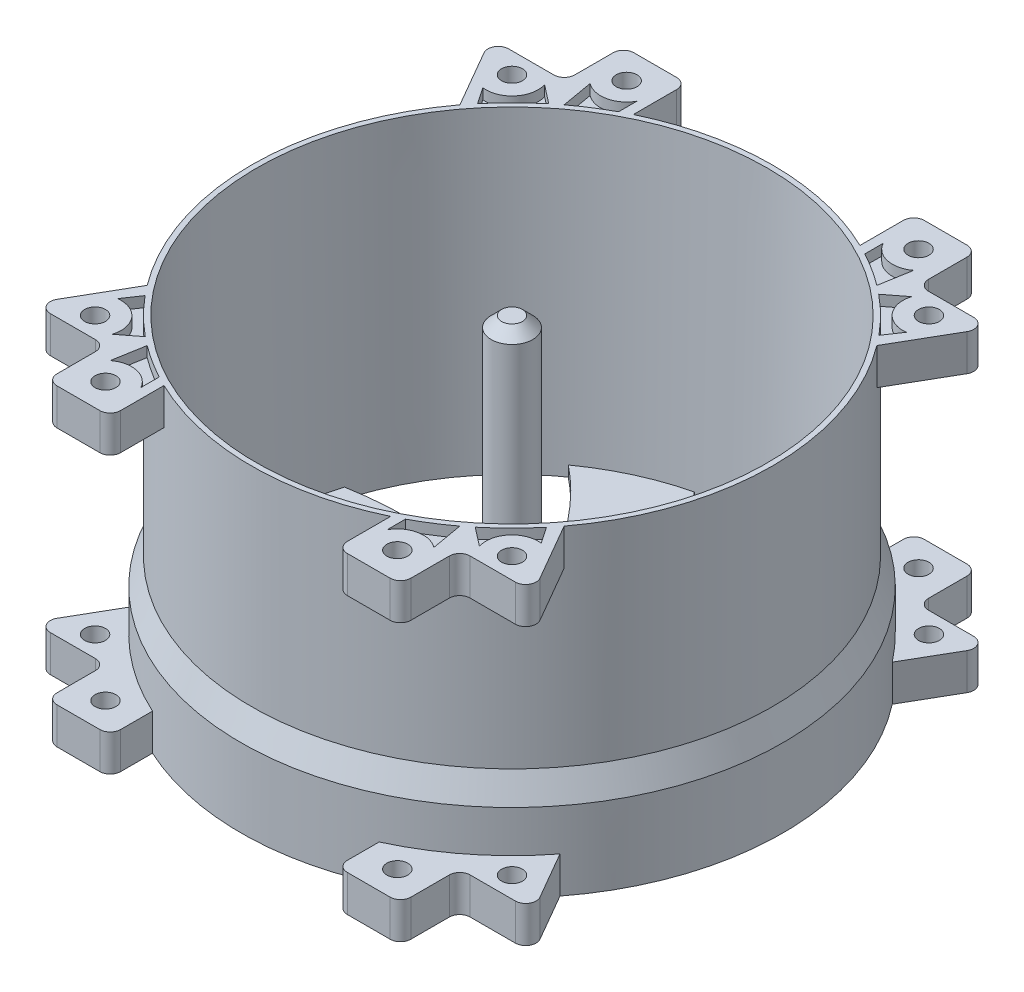
from build123d import *

# Parameters (mm, degrees)
SKETCH3_R               = 1
BOSS_EXTRUDE2_DEPTH     = 3.5
MIRROR2_COPY_1_SKETCH_R = 1
MIRROR2_COPY_1_DEPTH    = 3.5
MIRROR3_COPY_1_SKETCH_R = 1
MIRROR3_COPY_1_DEPTH    = 3.5
MIRROR3_COPY_2_SKETCH_R = 1
MIRROR3_COPY_2_DEPTH    = 3.5
MIRROR3_COPY_3_SKETCH_R = 1
MIRROR3_COPY_3_DEPTH    = 3.5
CUT_EXTRUDE1_DEPTH      = 1
MIRROR5_COPY_1_DEPTH    = 1
MIRROR7_COPY_1_DEPTH    = 1
MIRROR7_COPY_2_DEPTH    = 1
MIRROR7_COPY_3_DEPTH    = 1
BOSS_EXTRUDE3_DEPTH     = 1
SKETCH7_R               = 2.5
BOSS_EXTRUDE4_DEPTH     = 10
SKETCH8_R               = 2
BOSS_EXTRUDE5_DEPTH     = 19
CHAMFER1_SIZE           = 1


with BuildPart() as part:
    # Sketch1 → Revolve1 (revolve)
    with BuildSketch(Plane.XY):
        Polygon((-24.5, 30), (-25, 30), (-25, 10), (-26, 7.5), (-26, 0), (-23.75, 0), (-24, 10), align=None)
    revolve(axis=Axis((0, 0, 0), (0, 1, 0)))

    # Sketch3 → Boss-Extrude2 (add)
    with BuildSketch(Plane(origin=(0, 0, 0), x_dir=(1, 0, 0), z_dir=(0, 1, 0))):
        with BuildLine():
            Line((-10.872673426, 22.511885141), (-10.872673426, 26.672563638))
            ThreePointArc((-10.872673426, 26.672563638), (-11.165566644, 27.379670419), (-11.872673426, 27.672563638))
            Line((-11.872673426, 27.672563638), (-15.975816202, 27.672563638))
            ThreePointArc((-15.975816202, 27.672563638), (-16.682922984, 27.379670419), (-16.975816202, 26.672563638))
            Line((-16.975816202, 26.672563638), (-16.975816202, 22.989545507))
            ThreePointArc((-16.975816202, 22.989545507), (-17.268709421, 22.282438726), (-17.975816202, 21.989545507))
            Line((-17.975816202, 21.989545507), (-22.303365172, 21.989545507))
            ThreePointArc((-22.303365172, 21.989545507), (-23.169390576, 21.489545507), (-23.169390576, 20.489545507))
            Line((-23.169390576, 20.489545507), (-20, 15))
            ThreePointArc((-20, 15), (-15.886711293, 19.303170835), (-10.872673426, 22.511885141))
        make_face()
        with Locations((-14, 25)):
            Circle(SKETCH3_R, mode=Mode.SUBTRACT)
        with Locations((-20, 20)):
            Circle(SKETCH3_R, mode=Mode.SUBTRACT)
    boss_extrude2 = extrude(amount=BOSS_EXTRUDE2_DEPTH)

    # Mirror1: Boss-Extrude2 across plane
    add(boss_extrude2.mirror(Plane(origin=(0, 0, 0), x_dir=(0, 0, 1), z_dir=(1, 0, 0))))

    # Mirror2: Boss-Extrude2 across plane
    add(boss_extrude2.mirror(Plane.XY))

    # Mirror2 copy 1 sketch → Mirror2 copy 1 (add)
    with BuildSketch(Plane(origin=(0, 0, 0), x_dir=(-1, 0, 0), z_dir=(0, 1, 0))):
        with BuildLine():
            Line((-10.872673426, 22.511885141), (-10.872673426, 26.672563638))
            ThreePointArc((-10.872673426, 26.672563638), (-11.165566644, 27.379670419), (-11.872673426, 27.672563638))
            Line((-11.872673426, 27.672563638), (-15.975816202, 27.672563638))
            ThreePointArc((-15.975816202, 27.672563638), (-16.682922984, 27.379670419), (-16.975816202, 26.672563638))
            Line((-16.975816202, 26.672563638), (-16.975816202, 22.989545507))
            ThreePointArc((-16.975816202, 22.989545507), (-17.268709421, 22.282438726), (-17.975816202, 21.989545507))
            Line((-17.975816202, 21.989545507), (-22.303365172, 21.989545507))
            ThreePointArc((-22.303365172, 21.989545507), (-23.169390576, 21.489545507), (-23.169390576, 20.489545507))
            Line((-23.169390576, 20.489545507), (-20, 15))
            ThreePointArc((-20, 15), (-15.886711293, 19.303170835), (-10.872673426, 22.511885141))
        make_face()
        with Locations((-14, 25)):
            Circle(MIRROR2_COPY_1_SKETCH_R, mode=Mode.SUBTRACT)
        with Locations((-20, 20)):
            Circle(MIRROR2_COPY_1_SKETCH_R, mode=Mode.SUBTRACT)
    extrude(amount=MIRROR2_COPY_1_DEPTH)

    # Mirror3: Boss-Extrude2 across plane
    add(boss_extrude2.mirror(Plane(origin=(0, 15, 0), x_dir=(0, 0, 1), z_dir=(0, -1, 0))))

    # Mirror3 copy 1 sketch → Mirror3 copy 1 (add)
    with BuildSketch(Plane.XZ.offset(-30)):
        with BuildLine():
            Line((-10.872673426, 22.511885141), (-10.872673426, 26.672563638))
            ThreePointArc((-10.872673426, 26.672563638), (-11.165566644, 27.379670419), (-11.872673426, 27.672563638))
            Line((-11.872673426, 27.672563638), (-15.975816202, 27.672563638))
            ThreePointArc((-15.975816202, 27.672563638), (-16.682922984, 27.379670419), (-16.975816202, 26.672563638))
            Line((-16.975816202, 26.672563638), (-16.975816202, 22.989545507))
            ThreePointArc((-16.975816202, 22.989545507), (-17.268709421, 22.282438726), (-17.975816202, 21.989545507))
            Line((-17.975816202, 21.989545507), (-22.303365172, 21.989545507))
            ThreePointArc((-22.303365172, 21.989545507), (-23.169390576, 21.489545507), (-23.169390576, 20.489545507))
            Line((-23.169390576, 20.489545507), (-20, 15))
            ThreePointArc((-20, 15), (-15.886711293, 19.303170835), (-10.872673426, 22.511885141))
        make_face()
        with Locations((-14, 25)):
            Circle(MIRROR3_COPY_1_SKETCH_R, mode=Mode.SUBTRACT)
        with Locations((-20, 20)):
            Circle(MIRROR3_COPY_1_SKETCH_R, mode=Mode.SUBTRACT)
    extrude(amount=MIRROR3_COPY_1_DEPTH)

    # Mirror3 copy 2 sketch → Mirror3 copy 2 (add)
    with BuildSketch(Plane(origin=(0, 30, 0), x_dir=(-1, 0, 0), z_dir=(0, -1, 0))):
        with BuildLine():
            Line((-10.872673426, -22.511885141), (-10.872673426, -26.672563638))
            ThreePointArc((-10.872673426, -26.672563638), (-11.165566644, -27.379670419), (-11.872673426, -27.672563638))
            Line((-11.872673426, -27.672563638), (-15.975816202, -27.672563638))
            ThreePointArc((-15.975816202, -27.672563638), (-16.682922984, -27.379670419), (-16.975816202, -26.672563638))
            Line((-16.975816202, -26.672563638), (-16.975816202, -22.989545507))
            ThreePointArc((-16.975816202, -22.989545507), (-17.268709421, -22.282438726), (-17.975816202, -21.989545507))
            Line((-17.975816202, -21.989545507), (-22.303365172, -21.989545507))
            ThreePointArc((-22.303365172, -21.989545507), (-23.169390576, -21.489545507), (-23.169390576, -20.489545507))
            Line((-23.169390576, -20.489545507), (-20, -15))
            ThreePointArc((-20, -15), (-15.886711293, -19.303170835), (-10.872673426, -22.511885141))
        make_face()
        with Locations((-14, -25)):
            Circle(MIRROR3_COPY_2_SKETCH_R, mode=Mode.SUBTRACT)
        with Locations((-20, -20)):
            Circle(MIRROR3_COPY_2_SKETCH_R, mode=Mode.SUBTRACT)
    extrude(amount=MIRROR3_COPY_2_DEPTH)

    # Mirror3 copy 3 sketch → Mirror3 copy 3 (add)
    with BuildSketch(Plane(origin=(0, 30, 0), x_dir=(-1, 0, 0), z_dir=(0, -1, 0))):
        with BuildLine():
            Line((-10.872673426, 22.511885141), (-10.872673426, 26.672563638))
            ThreePointArc((-10.872673426, 26.672563638), (-11.165566644, 27.379670419), (-11.872673426, 27.672563638))
            Line((-11.872673426, 27.672563638), (-15.975816202, 27.672563638))
            ThreePointArc((-15.975816202, 27.672563638), (-16.682922984, 27.379670419), (-16.975816202, 26.672563638))
            Line((-16.975816202, 26.672563638), (-16.975816202, 22.989545507))
            ThreePointArc((-16.975816202, 22.989545507), (-17.268709421, 22.282438726), (-17.975816202, 21.989545507))
            Line((-17.975816202, 21.989545507), (-22.303365172, 21.989545507))
            ThreePointArc((-22.303365172, 21.989545507), (-23.169390576, 21.489545507), (-23.169390576, 20.489545507))
            Line((-23.169390576, 20.489545507), (-20, 15))
            ThreePointArc((-20, 15), (-15.886711293, 19.303170835), (-10.872673426, 22.511885141))
        make_face()
        with Locations((-14, 25)):
            Circle(MIRROR3_COPY_3_SKETCH_R, mode=Mode.SUBTRACT)
        with Locations((-20, 20)):
            Circle(MIRROR3_COPY_3_SKETCH_R, mode=Mode.SUBTRACT)
    extrude(amount=MIRROR3_COPY_3_DEPTH)

    # Sketch4 → Cut-Extrude1 (cut)
    with BuildSketch(Plane(origin=(0, 30, 0), x_dir=(1, 0, 0), z_dir=(0, 1, 0))):
        with BuildLine():
            Line((-19.251721054, 15.949019922), (-20.314309044, 17.519836734))
            ThreePointArc((-20.314309044, 17.519836734), (-18.085884655, 18.391845018), (-17.611180005, 20.737250996))
            Line((-17.611180005, 20.737250996), (-15.826569138, 19.352511706))
            ThreePointArc((-15.826569138, 19.352511706), (-17.621508158, 17.733653042), (-19.251721054, 15.949019922))
        make_face()
        with BuildLine():
            Line((-11.811012201, 22.034064328), (-11.811012201, 23.792385651))
            ThreePointArc((-11.811012201, 23.792385651), (-13.488202854, 22.552947961), (-15.521536705, 23.016335195))
            Line((-15.521536705, 23.016335195), (-15, 20))
            ThreePointArc((-15, 20), (-13.444030208, 21.077429914), (-11.811012201, 22.034064328))
        make_face()
    cut_extrude1 = extrude(amount=-CUT_EXTRUDE1_DEPTH, mode=Mode.SUBTRACT)

    # Mirror4: Cut-Extrude1 across plane
    add(cut_extrude1.mirror(Plane.XY), mode=Mode.SUBTRACT)

    # Mirror5: Cut-Extrude1 across plane
    add(cut_extrude1.mirror(Plane(origin=(0, 0, 0), x_dir=(0, 0, 1), z_dir=(1, 0, 0))), mode=Mode.SUBTRACT)

    # Mirror5 copy 1 sketch → Mirror5 copy 1 (cut)
    with BuildSketch(Plane(origin=(0, 30, 0), x_dir=(-1, 0, 0), z_dir=(0, 1, 0))):
        with BuildLine():
            Line((-19.251721054, 15.949019922), (-20.314309044, 17.519836734))
            ThreePointArc((-20.314309044, 17.519836734), (-18.085884655, 18.391845018), (-17.611180005, 20.737250996))
            Line((-17.611180005, 20.737250996), (-15.826569138, 19.352511706))
            ThreePointArc((-15.826569138, 19.352511706), (-17.621508158, 17.733653042), (-19.251721054, 15.949019922))
        make_face()
        with BuildLine():
            Line((-11.811012201, 22.034064328), (-11.811012201, 23.792385651))
            ThreePointArc((-11.811012201, 23.792385651), (-13.488202854, 22.552947961), (-15.521536705, 23.016335195))
            Line((-15.521536705, 23.016335195), (-15, 20))
            ThreePointArc((-15, 20), (-13.444030208, 21.077429914), (-11.811012201, 22.034064328))
        make_face()
    extrude(amount=-MIRROR5_COPY_1_DEPTH, mode=Mode.SUBTRACT)

    # Mirror7: Cut-Extrude1 across plane
    add(cut_extrude1.mirror(Plane(origin=(0, 15, 0), x_dir=(0, 0, 1), z_dir=(0, -1, 0))), mode=Mode.SUBTRACT)

    # Mirror7 copy 1 sketch → Mirror7 copy 1 (cut)
    with BuildSketch(Plane(origin=(0, 0, 0), x_dir=(-1, 0, 0), z_dir=(0, -1, 0))):
        with BuildLine():
            Line((-19.251721054, 15.949019922), (-20.314309044, 17.519836734))
            ThreePointArc((-20.314309044, 17.519836734), (-18.085884655, 18.391845018), (-17.611180005, 20.737250996))
            Line((-17.611180005, 20.737250996), (-15.826569138, 19.352511706))
            ThreePointArc((-15.826569138, 19.352511706), (-17.621508158, 17.733653042), (-19.251721054, 15.949019922))
        make_face()
        with BuildLine():
            Line((-11.811012201, 22.034064328), (-11.811012201, 23.792385651))
            ThreePointArc((-11.811012201, 23.792385651), (-13.488202854, 22.552947961), (-15.521536705, 23.016335195))
            Line((-15.521536705, 23.016335195), (-15, 20))
            ThreePointArc((-15, 20), (-13.444030208, 21.077429914), (-11.811012201, 22.034064328))
        make_face()
    extrude(amount=-MIRROR7_COPY_1_DEPTH, mode=Mode.SUBTRACT)

    # Mirror7 copy 2 sketch → Mirror7 copy 2 (cut)
    with BuildSketch(Plane(origin=(0, 0, 0), x_dir=(-1, 0, 0), z_dir=(0, -1, 0))):
        with BuildLine():
            Line((-19.251721054, -15.949019922), (-20.314309044, -17.519836734))
            ThreePointArc((-20.314309044, -17.519836734), (-18.085884655, -18.391845018), (-17.611180005, -20.737250996))
            Line((-17.611180005, -20.737250996), (-15.826569138, -19.352511706))
            ThreePointArc((-15.826569138, -19.352511706), (-17.621508158, -17.733653042), (-19.251721054, -15.949019922))
        make_face()
        with BuildLine():
            Line((-11.811012201, -22.034064328), (-11.811012201, -23.792385651))
            ThreePointArc((-11.811012201, -23.792385651), (-13.488202854, -22.552947961), (-15.521536705, -23.016335195))
            Line((-15.521536705, -23.016335195), (-15, -20))
            ThreePointArc((-15, -20), (-13.444030208, -21.077429914), (-11.811012201, -22.034064328))
        make_face()
    extrude(amount=-MIRROR7_COPY_2_DEPTH, mode=Mode.SUBTRACT)

    # Mirror7 copy 3 sketch → Mirror7 copy 3 (cut)
    with BuildSketch(Plane.XZ):
        with BuildLine():
            Line((-19.251721054, 15.949019922), (-20.314309044, 17.519836734))
            ThreePointArc((-20.314309044, 17.519836734), (-18.085884655, 18.391845018), (-17.611180005, 20.737250996))
            Line((-17.611180005, 20.737250996), (-15.826569138, 19.352511706))
            ThreePointArc((-15.826569138, 19.352511706), (-17.621508158, 17.733653042), (-19.251721054, 15.949019922))
        make_face()
        with BuildLine():
            Line((-11.811012201, 22.034064328), (-11.811012201, 23.792385651))
            ThreePointArc((-11.811012201, 23.792385651), (-13.488202854, 22.552947961), (-15.521536705, 23.016335195))
            Line((-15.521536705, 23.016335195), (-15, 20))
            ThreePointArc((-15, 20), (-13.444030208, 21.077429914), (-11.811012201, 22.034064328))
        make_face()
    extrude(amount=-MIRROR7_COPY_3_DEPTH, mode=Mode.SUBTRACT)


with BuildPart() as body_2:
    # Sketch5 → Boss-Extrude3 (new body)
    with BuildSketch(Plane.XZ):
        with BuildLine():
            ThreePointArc((-4.180120315, 1.521983551), (-4.262298929, 1.273831865), (-4.329760198, 1.021281748))
            add(Edge.make_bspline(
                [(-4.329760198, 1.021281748), (-5.266941613, 0.862729741), (-10.580768407, 0.108955412), (-17.232646716, 0.273964278), (-22.530462624, 1.948358427), (-23.630508897, 2.379401028)],
                knots=[0.186903198, 0.186903198, 0.186903198, 0.186903198, 0.30033875, 0.824971131, 0.966226479, 0.966226479, 0.966226479, 0.966226479], degree=3))
            ThreePointArc((-23.630508897, 2.379401028), (-23.647671099, -2.202305977), (-22.784753874, -6.702051246))
            add(Edge.make_bspline(
                [(-3.408136577, -2.859098608), (-8.897158975, -6.731322517), (-15.356031408, -8.01230673), (-22.784753874, -6.702051246)],
                knots=[0.177053159, 0.177053159, 0.177053159, 0.177053159, 1, 1, 1, 1], degree=3))
            ThreePointArc((-3.408136577, -2.859098608), (-3.23432022, -3.054343219), (-3.049336037, -3.23904145))
            add(Edge.make_bspline(
                [(-3.049336037, -3.23904145), (-3.380616679, -4.129940366), (-5.384742358, -9.108736526), (-8.853583383, -14.786927691), (-12.952559205, -18.537773778), (-13.875876185, -19.274920495)],
                knots=[0.186903198, 0.186903198, 0.186903198, 0.186903198, 0.30033875, 0.824971131, 0.966226479, 0.966226479, 0.966226479, 0.966226479], degree=3))
            ThreePointArc((-13.875876185, -19.274920495), (-9.916582626, -21.5806369), (-5.5882303, -23.083201297))
            add(Edge.make_bspline(
                [(0.771983738, -4.38108216), (1.380916813, -11.070826953), (-0.739154533, -17.304866665), (-5.5882303, -23.083201297)],
                knots=[0.177053159, 0.177053159, 0.177053159, 0.177053159, 1, 1, 1, 1], degree=3))
            ThreePointArc((0.771983738, -4.38108216), (1.02797871, -4.328175084), (1.280424161, -4.260323198))
            add(Edge.make_bspline(
                [(1.280424161, -4.260323198), (1.886324934, -4.992670108), (5.196026049, -9.217691938), (8.379063333, -15.06089197), (9.577903418, -20.486132205), (9.754632712, -21.654321524)],
                knots=[0.186903198, 0.186903198, 0.186903198, 0.186903198, 0.30033875, 0.824971131, 0.966226479, 0.966226479, 0.966226479, 0.966226479], degree=3))
            ThreePointArc((9.754632712, -21.654321524), (13.731088472, -19.378330923), (17.196523574, -16.381150051))
            add(Edge.make_bspline(
                [(4.180120315, -1.521983551), (10.278075788, -4.339504436), (14.616876874, -9.292559936), (17.196523574, -16.381150051)],
                knots=[0.177053159, 0.177053159, 0.177053159, 0.177053159, 1, 1, 1, 1], degree=3))
            ThreePointArc((4.180120315, -1.521983551), (4.262298929, -1.273831865), (4.329760198, -1.021281748))
            add(Edge.make_bspline(
                [(4.329760198, -1.021281748), (5.266941613, -0.862729741), (10.580768407, -0.108955412), (17.232646716, -0.273964278), (22.530462624, -1.948358427), (23.630508897, -2.379401028)],
                knots=[0.186903198, 0.186903198, 0.186903198, 0.186903198, 0.30033875, 0.824971131, 0.966226479, 0.966226479, 0.966226479, 0.966226479], degree=3))
            ThreePointArc((23.630508897, -2.379401028), (23.647671099, 2.202305977), (22.784753874, 6.702051246))
            add(Edge.make_bspline(
                [(3.408136577, 2.859098608), (8.897158975, 6.731322517), (15.356031408, 8.01230673), (22.784753874, 6.702051246)],
                knots=[0.177053159, 0.177053159, 0.177053159, 0.177053159, 1, 1, 1, 1], degree=3))
            ThreePointArc((3.408136577, 2.859098608), (3.23432022, 3.054343219), (3.049336037, 3.23904145))
            add(Edge.make_bspline(
                [(3.049336037, 3.23904145), (3.380616679, 4.129940366), (5.384742358, 9.108736526), (8.853583383, 14.786927691), (12.952559205, 18.537773778), (13.875876185, 19.274920495)],
                knots=[0.186903198, 0.186903198, 0.186903198, 0.186903198, 0.30033875, 0.824971131, 0.966226479, 0.966226479, 0.966226479, 0.966226479], degree=3))
            ThreePointArc((13.875876185, 19.274920495), (9.916582626, 21.5806369), (5.5882303, 23.083201297))
            add(Edge.make_bspline(
                [(-0.771983738, 4.38108216), (-1.380916813, 11.070826953), (0.739154533, 17.304866665), (5.5882303, 23.083201297)],
                knots=[0.177053159, 0.177053159, 0.177053159, 0.177053159, 1, 1, 1, 1], degree=3))
            ThreePointArc((-0.771983738, 4.38108216), (-1.02797871, 4.328175084), (-1.280424161, 4.260323198))
            add(Edge.make_bspline(
                [(-1.280424161, 4.260323198), (-1.886324934, 4.992670108), (-5.196026049, 9.217691938), (-8.379063333, 15.06089197), (-9.577903418, 20.486132205), (-9.754632712, 21.654321524)],
                knots=[0.186903198, 0.186903198, 0.186903198, 0.186903198, 0.30033875, 0.824971131, 0.966226479, 0.966226479, 0.966226479, 0.966226479], degree=3))
            ThreePointArc((-9.754632712, 21.654321524), (-13.731088472, 19.378330923), (-17.196523574, 16.381150051))
            add(Edge.make_bspline(
                [(-4.180120315, 1.521983551), (-10.278075788, 4.339504436), (-14.616876874, 9.292559936), (-17.196523574, 16.381150051)],
                knots=[0.177053159, 0.177053159, 0.177053159, 0.177053159, 1, 1, 1, 1], degree=3))
        make_face()
    extrude(amount=-BOSS_EXTRUDE3_DEPTH)

    # Sketch7 → Boss-Extrude4 (add)
    with BuildSketch(Plane(origin=(0, 1, 0), x_dir=(1, 0, 0), z_dir=(0, 1, 0))):
        Circle(SKETCH7_R)
    extrude(amount=BOSS_EXTRUDE4_DEPTH)

    # Sketch8 → Boss-Extrude5 (add)
    with BuildSketch(Plane(origin=(0, 11, 0), x_dir=(1, 0, 0), z_dir=(0, 1, 0))):
        Circle(SKETCH8_R)
    extrude(amount=BOSS_EXTRUDE5_DEPTH)

    # Chamfer1
    chamfer1_edges = [body_2.edges().sort_by_distance(p)[0] for p in [
        (-2, 30, 0),
    ]]
    chamfer(chamfer1_edges, length=CHAMFER1_SIZE)


solid = Compound([part.part, body_2.part])
